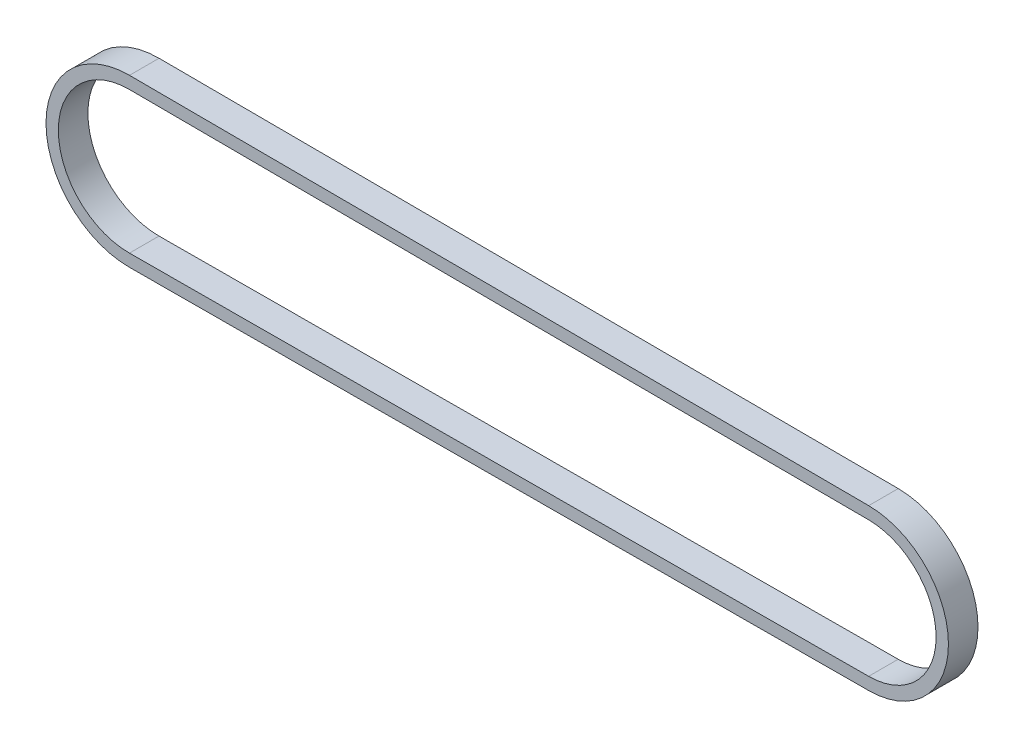
from build123d import *

# Parameters (mm, degrees)
SKETCH4_W = 2.4
SKETCH4_H = 1


with BuildPart() as part:
    # Sweep2: sweep along a path in Sketch2
    with BuildLine(Plane.XY) as sweep2_path:
        Line((0.026041667, 6.249945746), (60.025, 5.999947916))
        ThreePointArc((60.025, 5.999947916), (66, 0), (60.025, -5.999947916))
        Line((60.025, -5.999947916), (0.026041667, -6.249945746))
        ThreePointArc((0.026041667, -6.249945746), (-6.25, 0), (0.026041667, 6.249945746))
    # Sketch4 → Sweep2 (sweep)
    with BuildSketch(Plane(origin=(0, 0, 0), x_dir=(0, 0, -1), z_dir=(1, 0, 0))):
        with Locations((0, 6.25)):
            Rectangle(SKETCH4_W, SKETCH4_H)
    sweep(path=sweep2_path.line)


solid = part.part
